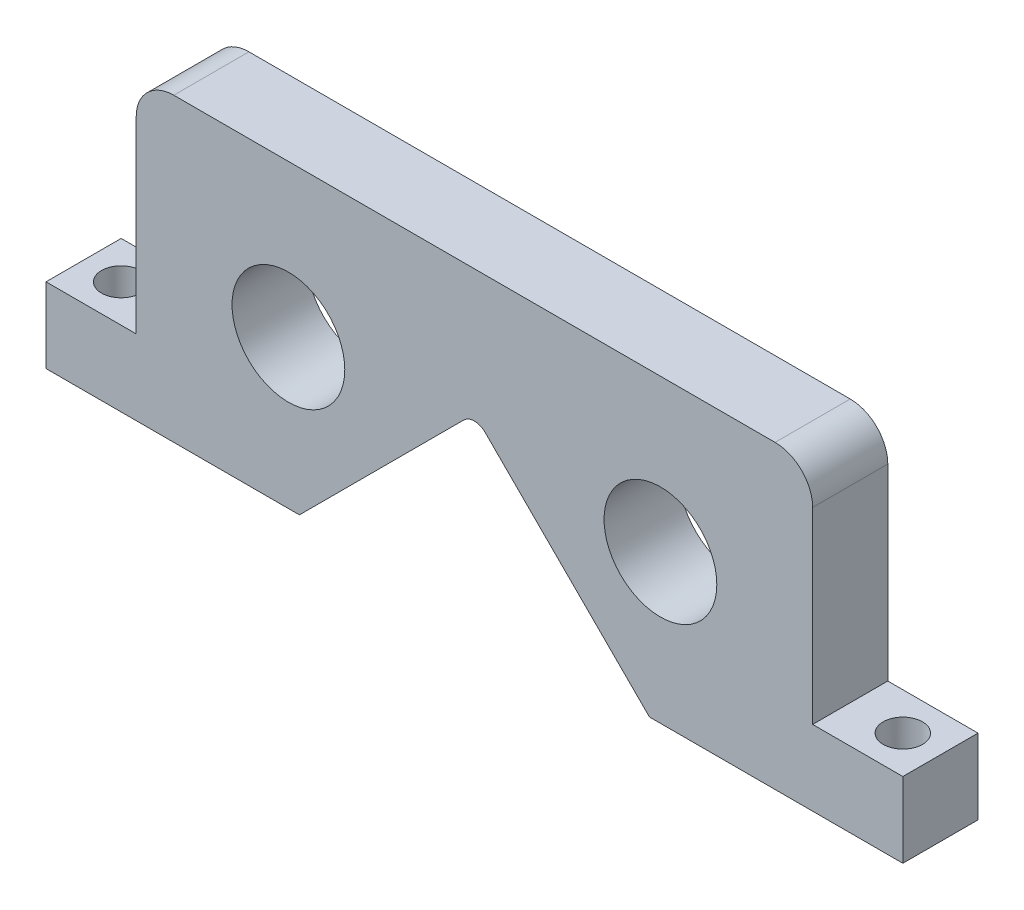
from build123d import *

# Parameters (mm, degrees)
SKETCH_1_R          = 7.5
EXTRUDE_1_DEPTH     = 5
SKETCH_2_R          = 2.612095194
CUT_EXTRUDE_1_DEPTH = 41


with BuildPart() as part:
    # 草圖1 → 填料-伸長1 (new body, symmetric)
    with BuildSketch(Plane.XY):
        with BuildLine():
            Line((-57, 15), (-57, 5))
            Line((-57, 5), (-23.284271247, 5))
            Line((-23.284271247, 5), (-1.414213562, 26.870057685))
            ThreePointArc((-1.414213562, 26.870057685), (0, 27.455844123), (1.414213562, 26.870057685))
            Line((1.414213562, 26.870057685), (23.284271247, 5))
            Line((23.284271247, 5), (57, 5))
            Line((57, 5), (57, 15))
            Line((57, 15), (45, 15))
            Line((45, 15), (45, 40))
            ThreePointArc((45, 40), (43.535533906, 43.535533906), (40, 45))
            Line((40, 45), (-40, 45))
            ThreePointArc((-40, 45), (-43.535533906, 43.535533906), (-45, 40))
            Line((-45, 40), (-45, 15))
            Line((-45, 15), (-57, 15))
        make_face()
        with Locations((-24.748737342, 24.748737342)):
            Circle(SKETCH_1_R, mode=Mode.SUBTRACT)
        with Locations((24.748737342, 24.748737342)):
            Circle(SKETCH_1_R, mode=Mode.SUBTRACT)
    extrude(amount=EXTRUDE_1_DEPTH, both=True)

    # 草圖2 → 除料-伸長1 (cut, through all)
    with BuildSketch(Plane.XZ.offset(-5)):
        with Locations((-52, 0)):
            Circle(SKETCH_2_R)
        with Locations((52, 0)):
            Circle(SKETCH_2_R)
    extrude(amount=-CUT_EXTRUDE_1_DEPTH, mode=Mode.SUBTRACT)


solid = part.part
